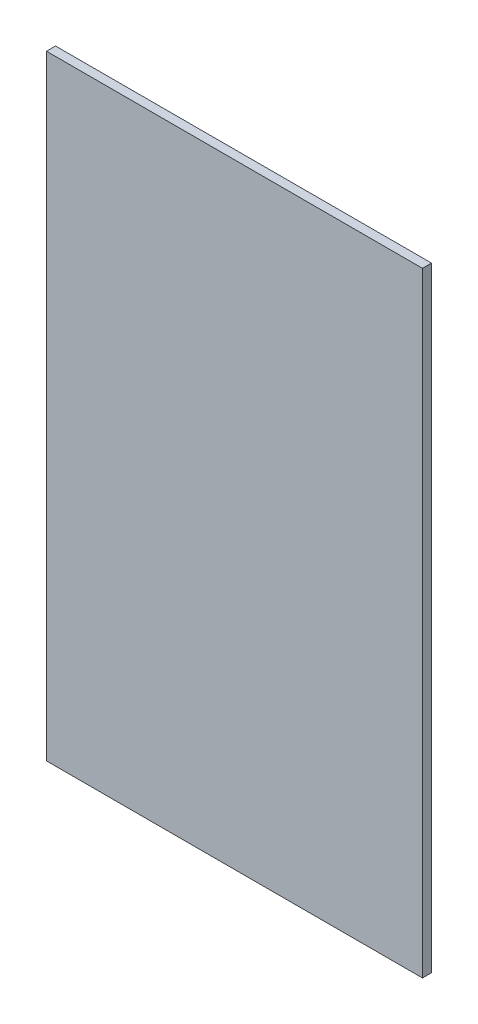
from build123d import *

# Parameters (mm, degrees)
SKETCH1_W           = 208
SKETCH1_H           = 400
BOSS_EXTRUDE1_DEPTH = 2.5
SKETCH2_W           = 359.169173544
SKETCH2_H           = 71.825535335
CUT_EXTRUDE1_DEPTH  = 6


with BuildPart() as part:
    # Sketch1 → Boss-Extrude1 (new body, symmetric)
    with BuildSketch(Plane.XY):
        Rectangle(SKETCH1_W, SKETCH1_H)
    extrude(amount=BOSS_EXTRUDE1_DEPTH, both=True)

    # Sketch2 → Cut-Extrude1 (cut, through all)
    with BuildSketch(Plane.XY.offset(2.5)):
        with Locations((24.370605125, 175.912767668)):
            Rectangle(SKETCH2_W, SKETCH2_H)
    extrude(amount=-CUT_EXTRUDE1_DEPTH, mode=Mode.SUBTRACT)


solid = part.part
